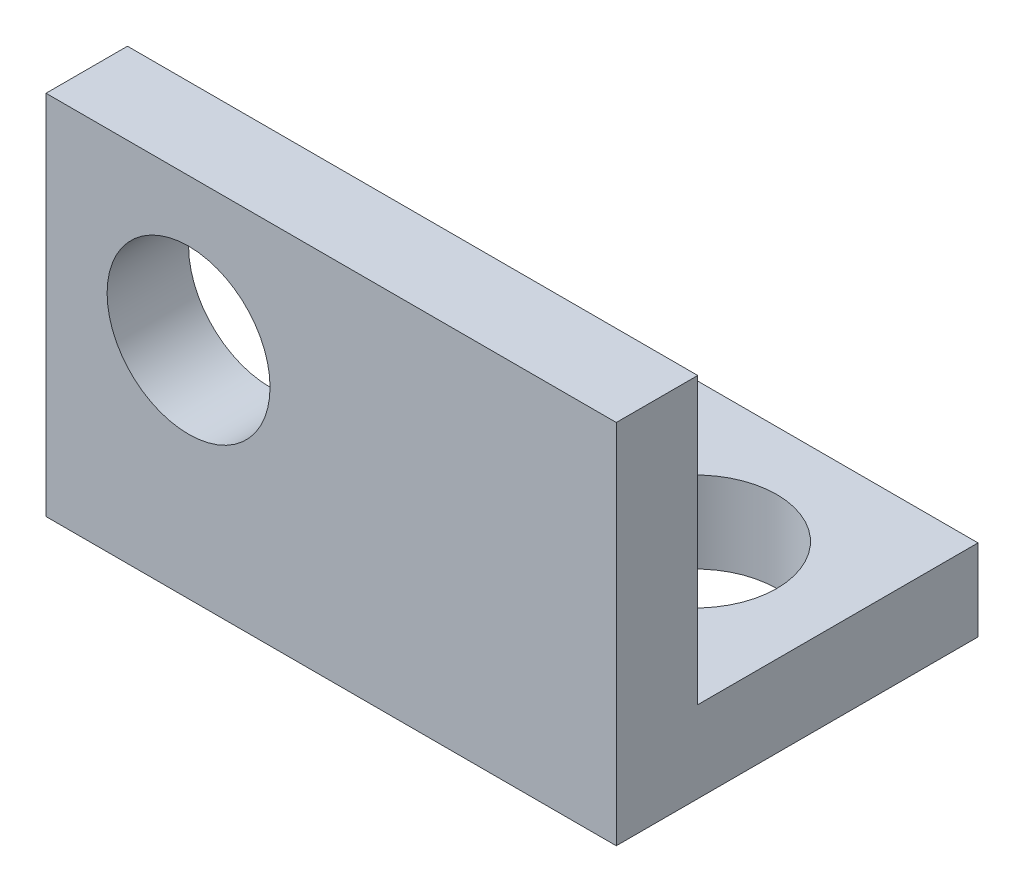
from build123d import *

# Parameters (mm, degrees)
SKETCH1_W           = 8.89
SKETCH1_H           = 11.2776
SKETCH1_R           = 2.54
BOSS_EXTRUDE1_DEPTH = 2.54
SKETCH4_W           = 17.78
SKETCH4_H           = 11.43
SKETCH4_R           = 2.54
BOSS_EXTRUDE2_DEPTH = 2.54


with BuildPart() as part:
    # Sketch1 → Boss-Extrude1 (new body)
    with BuildSketch(Plane(origin=(0, 0, 0), x_dir=(1, 0, 0), z_dir=(0, 1, 0))):
        with Locations((-4.445, -5.6388)):
            Rectangle(SKETCH1_W, SKETCH1_H)
        with Locations((-4.445, -4.3688)):
            Circle(SKETCH1_R, mode=Mode.SUBTRACT)
    extrude(amount=BOSS_EXTRUDE1_DEPTH)

    # Sketch4 → Boss-Extrude2 (add)
    with BuildSketch(Plane.XY.offset(11.2776)):
        with Locations((-8.89, 5.715)):
            Rectangle(SKETCH4_W, SKETCH4_H)
        with Locations((-13.335, 6.985)):
            Circle(SKETCH4_R, mode=Mode.SUBTRACT)
    extrude(amount=-BOSS_EXTRUDE2_DEPTH)


solid = part.part
